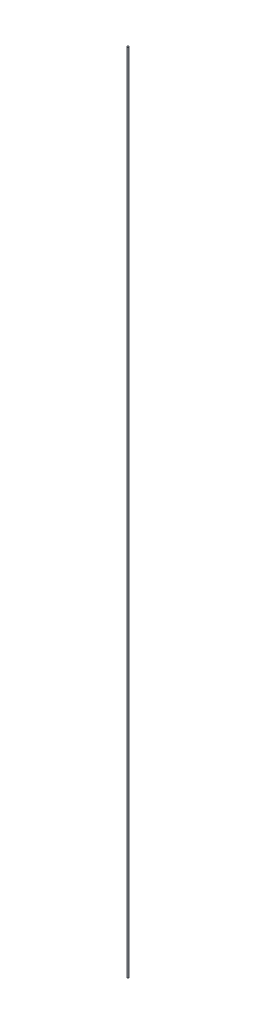
from build123d import *

# Parameters (mm, degrees)
SKETCH_1_R      = 1
EXTRUDE_1_DEPTH = 1000


with BuildPart() as part:
    # 草图1 → 凸台-拉伸1 (new body)
    with BuildSketch(Plane(origin=(0, 0, 0), x_dir=(1, 0, 0), z_dir=(0, 1, 0))):
        Circle(SKETCH_1_R)
    extrude(amount=EXTRUDE_1_DEPTH)


solid = part.part
